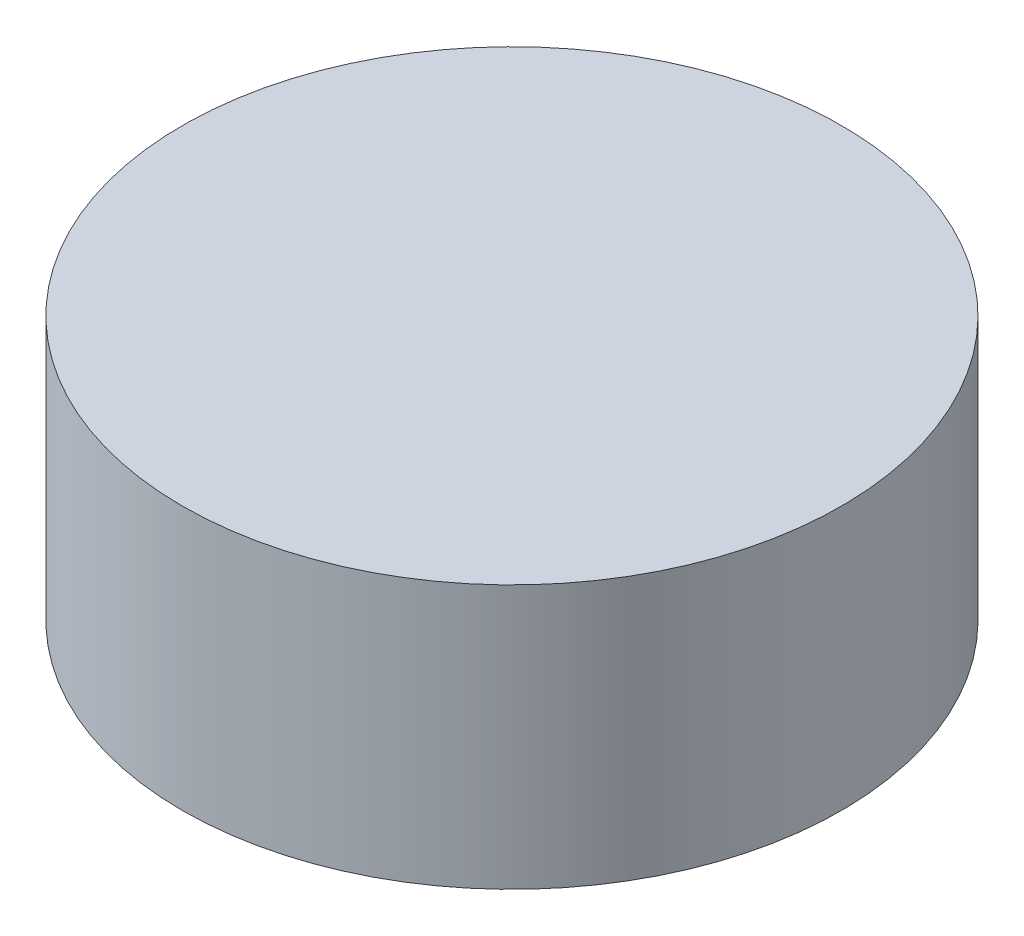
from build123d import *

# Parameters (mm, degrees)
SKETCH2_R           = 32.5
BOSS_EXTRUDE1_DEPTH = 26
SKETCH3_R           = 4
BOSS_EXTRUDE2_DEPTH = 4.5


with BuildPart() as part:
    # Sketch2 → Boss-Extrude1 (new body)
    with BuildSketch(Plane(origin=(0, 0, 0), x_dir=(1, 0, 0), z_dir=(0, 1, 0))):
        Circle(SKETCH2_R)
    extrude(amount=BOSS_EXTRUDE1_DEPTH)

    # Sketch3 → Boss-Extrude2 (add)
    with BuildSketch(Plane.XZ):
        Circle(SKETCH3_R)
    extrude(amount=BOSS_EXTRUDE2_DEPTH)


solid = part.part
